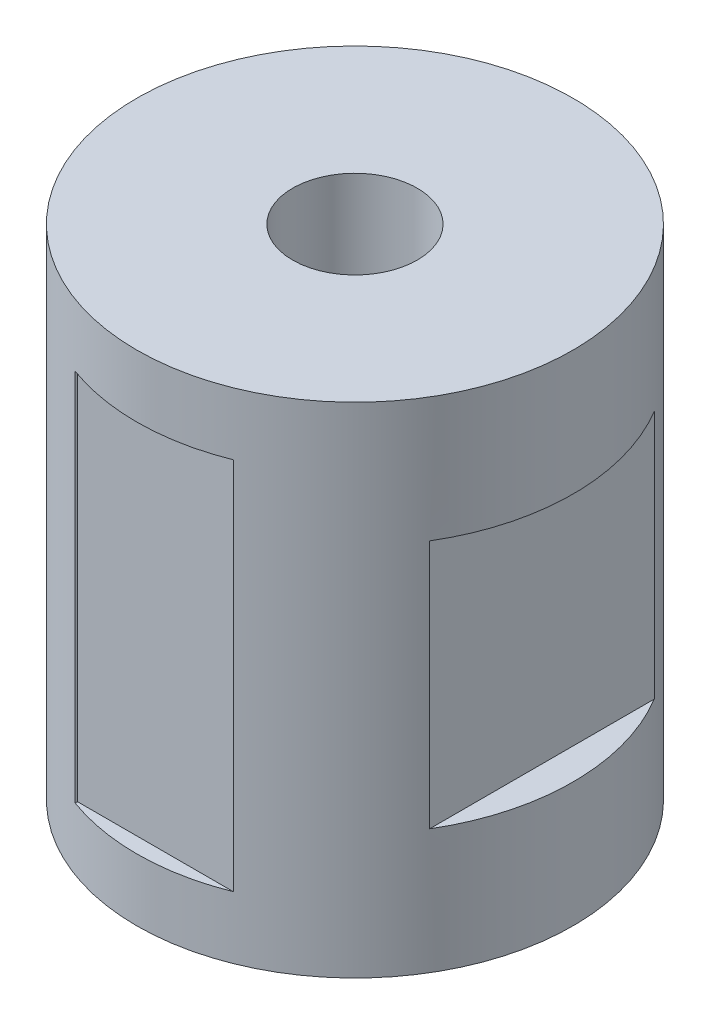
from build123d import *

# Parameters (mm, degrees)
SKETCH1_R           = 350
SKETCH1_R_2         = 100
BOSS_EXTRUDE1_DEPTH = 800
SKETCH2_W           = 250
SKETCH2_H           = 600
CUT_EXTRUDE1_DEPTH  = 25
SKETCH3_W           = 366
SKETCH3_H           = 400
CUT_EXTRUDE2_DEPTH  = 50


with BuildPart() as part:
    # Sketch1 → Boss-Extrude1 (new body)
    with BuildSketch(Plane(origin=(0, 0, 0), x_dir=(1, 0, 0), z_dir=(0, 1, 0))):
        Circle(SKETCH1_R)
        Circle(SKETCH1_R_2, mode=Mode.SUBTRACT)
    extrude(amount=BOSS_EXTRUDE1_DEPTH)

    # Sketch2 → Cut-Extrude1 (cut)
    with BuildSketch(Plane.XY.offset(350)):
        with Locations((5, 400)):
            Rectangle(SKETCH2_W, SKETCH2_H)
    extrude(amount=-CUT_EXTRUDE1_DEPTH, mode=Mode.SUBTRACT)

    # Sketch3 → Cut-Extrude2 (cut)
    with BuildSketch(Plane(origin=(350, 0, 0), x_dir=(0, 0, -1), z_dir=(1, 0, 0))):
        with Locations((-2.7, 400)):
            Rectangle(SKETCH3_W, SKETCH3_H)
    extrude(amount=-CUT_EXTRUDE2_DEPTH, mode=Mode.SUBTRACT)


solid = part.part
